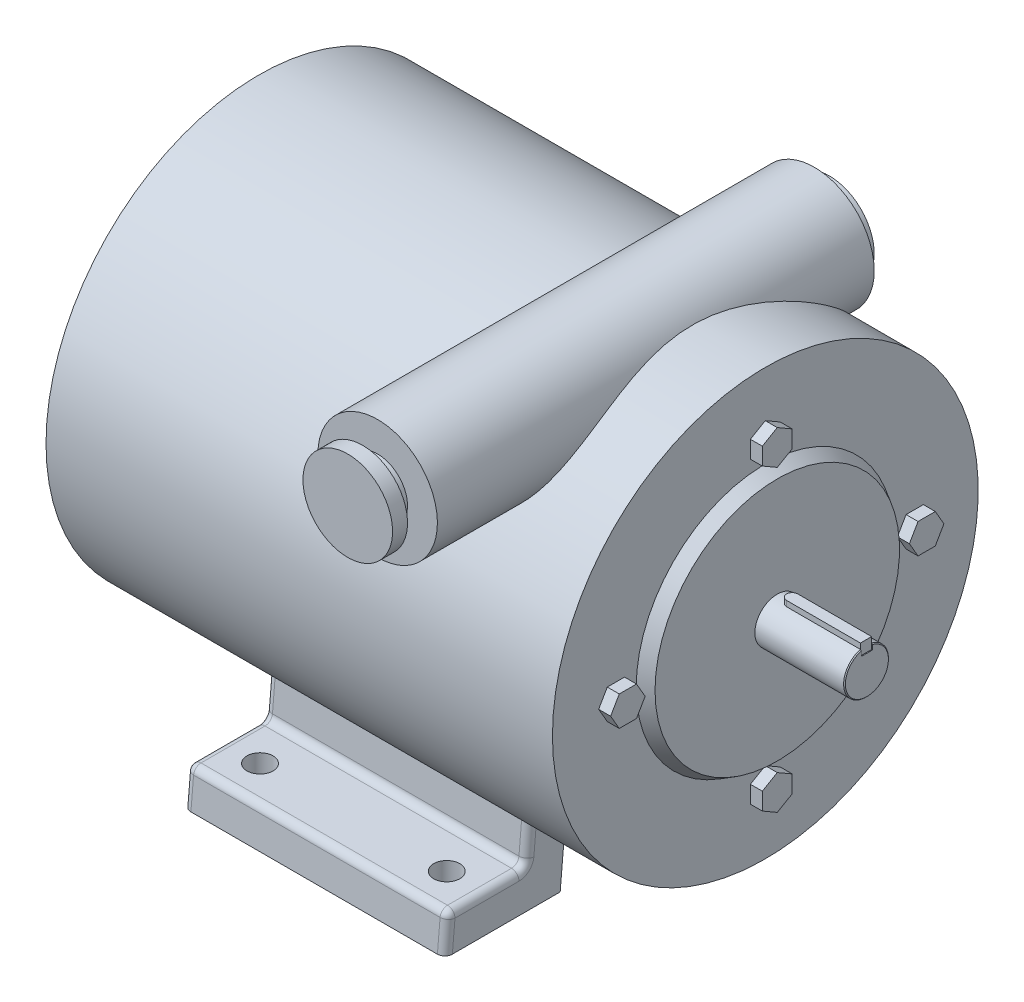
from build123d import *

# Parameters (mm, degrees)
SKETCH1_R              = 9.525
BOSS_EXTRUDE1_DEPTH    = 150.8125
SKETCH2_R              = 90.4875
BOSS_EXTRUDE2_DEPTH    = 12.7
SKETCH3_W              = 202.565
SKETCH3_H              = 90.4875
BOSS_EXTRUDE3_DEPTH    = 111.125
FILLET1_R              = 3.175
SKETCH7_R              = 5.55625
DD5ALS_AND_DD15A_DEPTH = 16.875
CHAMFER1_SIZE          = 0.381
CUT_EXTRUDE8_DEPTH     = 31.75
BOSS_EXTRUDE4_DEPTH    = 4.7625
SKETCH12_R             = 25.4
BOSS_EXTRUDE5_DEPTH    = 204.724
SKETCH13_W             = 6.35
SKETCH13_H             = 6.35
BOSS_EXTRUDE6_DEPTH    = 5.08
BOSS_EXTRUDE6_2_DEPTH  = 5.08
BOSS_EXTRUDE6_3_DEPTH  = 5.08
BOSS_EXTRUDE6_4_DEPTH  = 5.08
SKETCH18_R             = 54.897651581
BOSS_EXTRUDE7_DEPTH    = 5.08
BOSS_EXTRUDE7_TAPER    = 30


with BuildPart() as part:
    # Sketch1 → Boss-Extrude1 (new body, symmetric)
    with BuildSketch(Plane(origin=(0, 0, 0), x_dir=(0, 0, -1), z_dir=(1, 0, 0))):
        Circle(SKETCH1_R)
    extrude(amount=BOSS_EXTRUDE1_DEPTH, both=True)

    # Sketch2 → Boss-Extrude2 (add)
    with BuildSketch(Plane.ZY.offset(107.6325)):
        Circle(SKETCH2_R)
    extrude(amount=-BOSS_EXTRUDE2_DEPTH)

    # Sketch3 → Revolve1 (revolve)
    with BuildSketch(Plane.XY, mode=Mode.PRIVATE) as revolve1_sk:
        with Locations((6.35, 45.24375)):
            Rectangle(SKETCH3_W, SKETCH3_H)
    revolve(revolve1_sk.sketch.rotate(Axis((107.6325, 0, 0), (1, 0, 0)), 90), axis=Axis((107.6325, 0, 0), (1, 0, 0)))  # turned: the seam where the file's is

    # Sketch4 → Boss-Extrude3 (add)
    with BuildSketch(Plane(origin=(58.7375, 0, 0), x_dir=(0, 0, -1), z_dir=(1, 0, 0))):
        Polygon((-87.3125, -107.95), (-38.295988523, -107.95), (-36.110520174, -82.969982458), (-51.365600645, -74.495387284), (-52.903617467, -92.075), (-85.923617467, -92.075), align=None)
        Polygon((87.3125, -107.95), (85.923617467, -92.075), (52.903617467, -92.075), (51.365600645, -74.495387284), (36.110520174, -82.969982458), (38.295988523, -107.95), align=None)
    extrude(amount=-BOSS_EXTRUDE3_DEPTH)

    # Fillet1
    fillet1_edges = [part.edges().sort_by_distance(p)[0] for p in [
        (-52.3875, -100.0125, 86.618058733),
        (-52.3875, -92.075, 69.413617467),
        (3.175, -92.075, 85.923617467),
        (-52.3875, -83.285193642, 52.134609056),
        (3.175, -92.075, 52.903617467),
        (3.175, -82.969982458, 36.110520174),
        (58.7375, -83.285193642, 52.134609056),
        (58.7375, -92.075, 69.413617467),
        (58.7375, -100.0125, 86.618058733),
        (3.175, -82.969982458, -36.110520174),
        (-52.3875, -83.285193642, -52.134609056),
        (-52.3875, -92.075, -69.413617467),
        (3.175, -92.075, -52.903617467),
        (-52.3875, -100.0125, -86.618058733),
        (3.175, -92.075, -85.923617467),
        (58.7375, -83.285193642, -52.134609056),
        (58.7375, -100.0125, -86.618058733),
        (58.7375, -92.075, -69.413617467),
    ]]
    fillet(fillet1_edges, radius=FILLET1_R)

    # Sketch7 → DD5ALS AND DD15A (cut, through all)
    with BuildSketch(Plane(origin=(0, -92.075, 0), x_dir=(1, 0, 0), z_dir=(0, 1, 0))):
        with Locations(Location((42.8625, -70.64375, 0), (0, 0, 270))):  # turned: the seam where the file's is
            Circle(SKETCH7_R)
        with Locations(Location((-36.5125, -70.64375, 0), (0, 0, 270))):  # turned: the seam where the file's is
            Circle(SKETCH7_R)
        with Locations(Location((42.8625, 70.64375, 0), (0, 0, 90))):  # turned: the seam where the file's is
            Circle(SKETCH7_R)
        with Locations(Location((-36.5125, 70.64375, 0), (0, 0, 90))):  # turned: the seam where the file's is
            Circle(SKETCH7_R)
    extrude(amount=-DD5ALS_AND_DD15A_DEPTH, mode=Mode.SUBTRACT)

    # Chamfer1
    chamfer1_edges = [part.edges().sort_by_distance(p)[0] for p in [
        (-150.8125, 0, 9.525),
        (150.8125, 0, 9.525),
    ]]
    chamfer(chamfer1_edges, length=CHAMFER1_SIZE)

    # Sketch10 → Cut-Extrude8 (cut)
    with BuildSketch(Plane.ZY.offset(150.8125)):
        Polygon((-2.38125, 9.222541593), (-2.38125, 9.525), (2.38125, 9.525), (2.38125, 9.222541593), (2.38125, 6.8072), (-2.38125, 6.8072), align=None)
    cut_extrude8 = extrude(amount=-CUT_EXTRUDE8_DEPTH, mode=Mode.SUBTRACT)

    # Mirror2: Cut-Extrude8 across plane
    add(cut_extrude8.mirror(Plane(origin=(0, 0, 0), x_dir=(0, 0, 1), z_dir=(1, 0, 0))), mode=Mode.SUBTRACT)


with BuildPart() as body_2:
    # Sketch11 → Boss-Extrude4 (new body)
    with BuildSketch(Plane(origin=(0, 6.8072, 0), x_dir=(1, 0, 0), z_dir=(0, 1, 0))):
        with BuildLine():
            Line((-150.4315, 2.38125), (-150.4315, -2.38125))
            Line((-150.4315, -2.38125), (-119.0625, -2.38125))
            ThreePointArc((-119.0625, -2.38125), (-116.68125, 0), (-119.0625, 2.38125))
            Line((-119.0625, 2.38125), (-150.4315, 2.38125))
        make_face()
    extrude(amount=BOSS_EXTRUDE4_DEPTH)


with BuildPart() as body_3:
    # Mirror3: mirrored copy
    add(body_2.part.mirror(Plane(origin=(0, 0, 0), x_dir=(0, 0, 1), z_dir=(1, 0, 0))))


with BuildPart() as body_4:
    # Sketch12 → Boss-Extrude5 (new body)
    with BuildSketch(Plane.XY.offset(125.4125)):
        with Locations((55.5625, 76.2)):
            Circle(SKETCH12_R)
    extrude(amount=-BOSS_EXTRUDE5_DEPTH)

    # Sketch13 → Cut-Revolve1 (revolve, cut)
    with BuildSketch(Plane(origin=(55.5625, 0, 0), x_dir=(0, 0, -1), z_dir=(1, 0, 0)), mode=Mode.PRIVATE) as cut_revolve1_sk:
        Polygon((-125.4125, 95.25), (-119.0625, 95.25), (-119.0625, 88.9), (-112.7125, 88.9), (-112.7125, 101.6), (-125.4125, 101.6), align=None)
        with Locations((76.1365, 98.425)):
            Rectangle(SKETCH13_W, SKETCH13_H)
    revolve(cut_revolve1_sk.sketch.rotate(Axis((55.5625, 76.2, -79.3115), (0, 0, 1)), 90), axis=Axis((55.5625, 76.2, -79.3115), (0, 0, 1)), mode=Mode.SUBTRACT)  # turned: the seam where the file's is


with BuildPart() as body_5:
    # Sketch16 → Boss-Extrude6 (new body)
    with BuildSketch(Plane.ZY.offset(112.7125)):
        Polygon((56.167651581, 0), (59.833825791, -6.35), (67.166174209, -6.35), (70.832348419, 0), (67.166174209, 6.35), (59.833825791, 6.35), align=None)
    extrude(amount=-BOSS_EXTRUDE6_DEPTH)


with BuildPart() as body_6:
    # Sketch16 → Boss-Extrude6 2 (new body)
    with BuildSketch(Plane.ZY.offset(112.7125)):
        Polygon((0, 56.167651581), (6.35, 59.833825791), (6.35, 67.166174209), (0, 70.832348419), (-6.35, 67.166174209), (-6.35, 59.833825791), align=None)
    extrude(amount=-BOSS_EXTRUDE6_2_DEPTH)


with BuildPart() as body_7:
    # Sketch16 → Boss-Extrude6 3 (new body)
    with BuildSketch(Plane.ZY.offset(112.7125)):
        Polygon((0, -56.167651581), (-6.35, -59.833825791), (-6.35, -67.166174209), (0, -70.832348419), (6.35, -67.166174209), (6.35, -59.833825791), align=None)
    extrude(amount=-BOSS_EXTRUDE6_3_DEPTH)


with BuildPart() as body_8:
    # Sketch16 → Boss-Extrude6 4 (new body)
    with BuildSketch(Plane.ZY.offset(112.7125)):
        Polygon((-56.167651581, 0), (-59.833825791, 6.35), (-67.166174209, 6.35), (-70.832348419, 0), (-67.166174209, -6.35), (-59.833825791, -6.35), align=None)
    extrude(amount=-BOSS_EXTRUDE6_4_DEPTH)


with BuildPart() as body_9:
    # Sketch18 → Boss-Extrude7 (new body)
    with BuildSketch(Plane.ZY.offset(107.6325)):
        Circle(SKETCH18_R)
    extrude(amount=BOSS_EXTRUDE7_DEPTH, taper=BOSS_EXTRUDE7_TAPER)


with BuildPart() as body_10:
    # Mirror4: mirrored copy
    add(body_5.part.mirror(Plane(origin=(0, 0, 0), x_dir=(0, 0, 1), z_dir=(1, 0, 0))))


with BuildPart() as body_11:
    # Mirror4 2: mirrored copy
    add(body_7.part.mirror(Plane(origin=(0, 0, 0), x_dir=(0, 0, 1), z_dir=(1, 0, 0))))


with BuildPart() as body_12:
    # Mirror4 3: mirrored copy
    add(body_9.part.mirror(Plane(origin=(0, 0, 0), x_dir=(0, 0, 1), z_dir=(1, 0, 0))))


with BuildPart() as body_13:
    # Mirror4 4: mirrored copy
    add(body_6.part.mirror(Plane(origin=(0, 0, 0), x_dir=(0, 0, 1), z_dir=(1, 0, 0))))


with BuildPart() as body_14:
    # Mirror4 5: mirrored copy
    add(body_8.part.mirror(Plane(origin=(0, 0, 0), x_dir=(0, 0, 1), z_dir=(1, 0, 0))))


with BuildPart() as body_3_1:
    add(body_3.part)

    # Combine1: union body 2, body 4, body 7, body 5, body 9, body 6, body 8, part, body 10, body 12, body 11, body 14, body 13
    add(body_2.part)
    add(body_4.part)
    add(body_7.part)
    add(body_5.part)
    add(body_9.part)
    add(body_6.part)
    add(body_8.part)
    add(part.part)
    add(body_10.part)
    add(body_12.part)
    add(body_11.part)
    add(body_14.part)
    add(body_13.part)


solid = body_3_1.part
